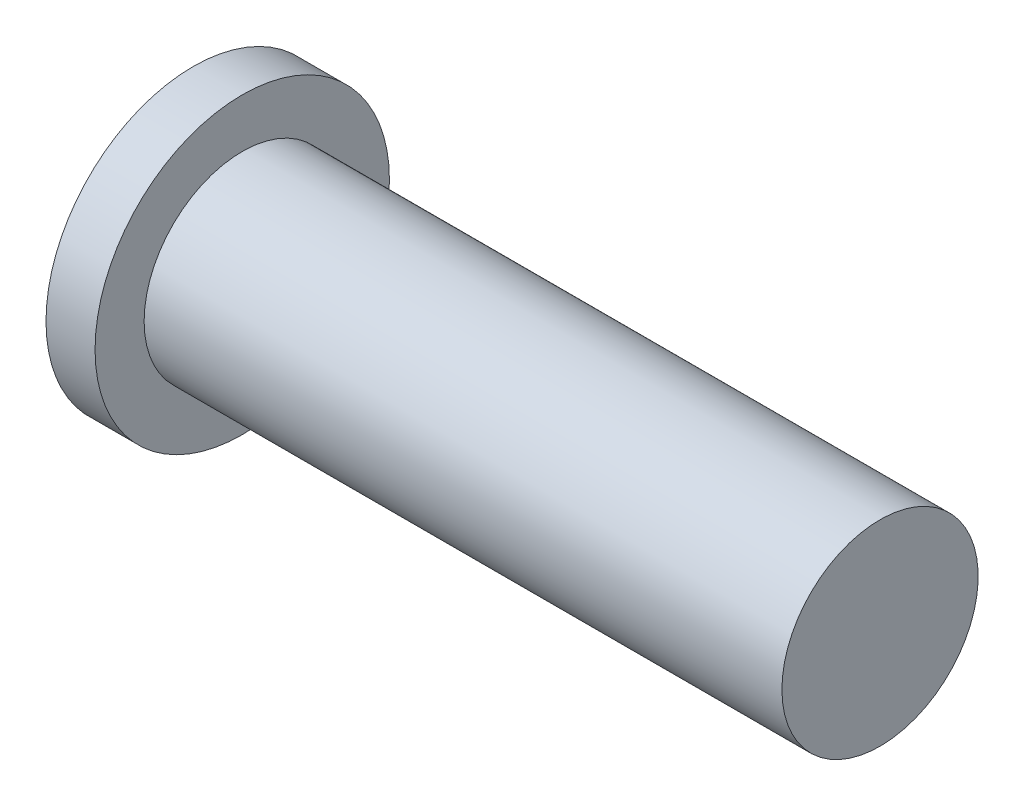
from build123d import *


with BuildPart() as part:
    # BodySke → Base-Revolve (revolve)
    with BuildSketch(Plane.XY):
        Polygon((3.1, 2), (3.1, 3), (2.1, 3), (2.1, 0), (16.1, 0), (16.1, 2), align=None)
    revolve(axis=Axis((-25.4, 0, 0), (1, 0, 0)))


solid = part.part
